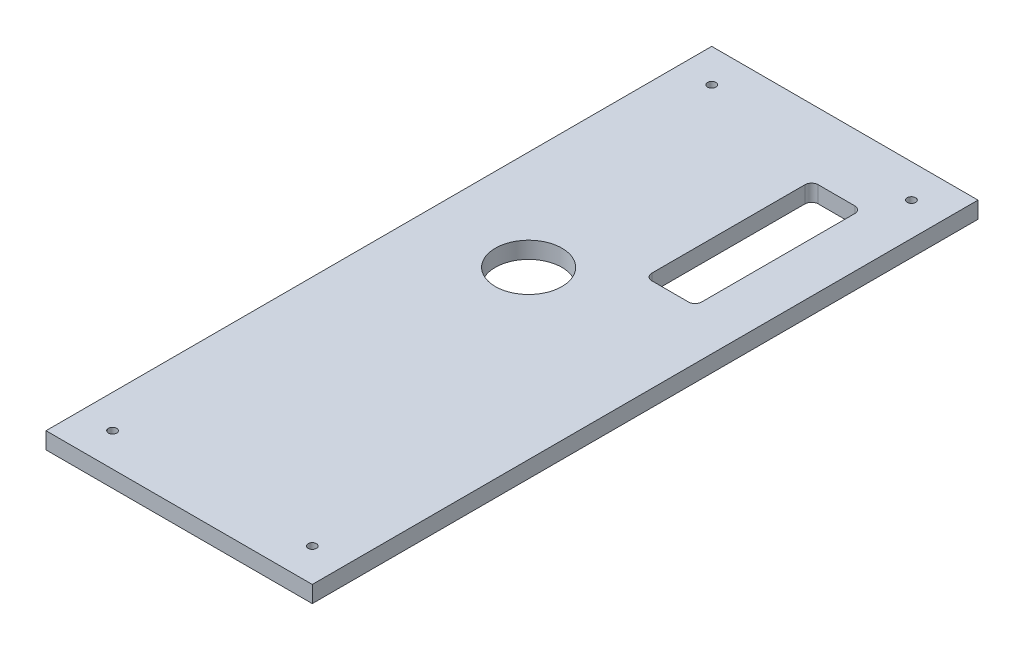
from build123d import *

# Parameters (mm, degrees)
SKETCH1_W           = 101.6
SKETCH1_H           = 254
SKETCH1_R           = 12.7
SKETCH1_R_2         = 1.5875
BOSS_EXTRUDE1_DEPTH = 6.35


with BuildPart() as part:
    # Sketch1 → Boss-Extrude1 (new body)
    with BuildSketch(Plane(origin=(0, 0, 0), x_dir=(1, 0, 0), z_dir=(0, 1, 0))):
        Rectangle(SKETCH1_W, SKETCH1_H)
        with Locations((-12.7, 19.05)):
            Circle(SKETCH1_R, mode=Mode.SUBTRACT)
        with Locations((-38.1, -114.3)):
            Circle(SKETCH1_R_2, mode=Mode.SUBTRACT)
        with Locations((38.1, -114.3)):
            Circle(SKETCH1_R_2, mode=Mode.SUBTRACT)
        with Locations((38.1, 114.3)):
            Circle(SKETCH1_R_2, mode=Mode.SUBTRACT)
        with Locations((-38.1, 114.3)):
            Circle(SKETCH1_R_2, mode=Mode.SUBTRACT)
        with BuildLine():
            Line((29.21, 101.6), (15.24, 101.6))
            ThreePointArc((15.24, 101.6), (13.443948776, 100.856051224), (12.7, 99.06))
            Line((12.7, 99.06), (12.7, 40.64))
            ThreePointArc((12.7, 40.64), (13.443948776, 38.843948776), (15.24, 38.1))
            Line((15.24, 38.1), (29.21, 38.1))
            ThreePointArc((29.21, 38.1), (31.006051224, 38.843948776), (31.75, 40.64))
            Line((31.75, 40.64), (31.75, 99.06))
            ThreePointArc((31.75, 99.06), (31.006051224, 100.856051224), (29.21, 101.6))
        make_face(mode=Mode.SUBTRACT)
    extrude(amount=BOSS_EXTRUDE1_DEPTH)


solid = part.part
